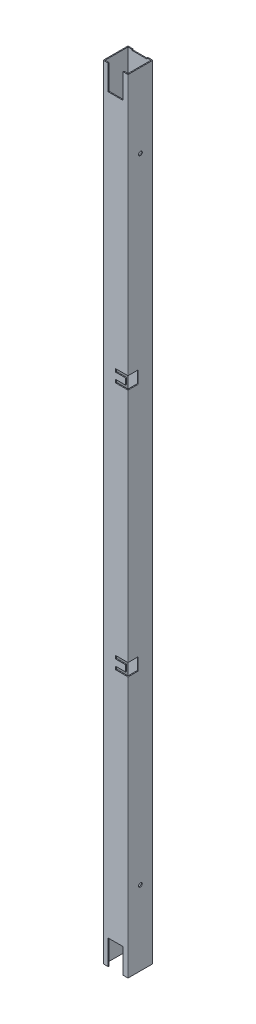
from build123d import *

# Parameters (mm, degrees)
SKETCH1_W           = 37
SKETCH1_H           = 37
BOSS_EXTRUDE1_DEPTH = 1260
SKETCH2_W           = 23.9
SKETCH2_H           = 40
CUT_EXTRUDE1_DEPTH  = 20
SKETCH3_W           = 23.9
SKETCH3_H           = 1.6
CUT_EXTRUDE2_DEPTH  = 20
CUT_EXTRUDE3_DEPTH  = 20
SKETCH5_W           = 4
SKETCH5_H           = 10
CUT_EXTRUDE4_DEPTH  = 10
LPATTERN1_COUNT     = 2
LPATTERN1_PITCH     = 400
SKETCH6_R           = 3
CUT_EXTRUDE5_DEPTH  = 1262.269202034


with BuildPart() as part:
    # Sketch1 → Boss-Extrude1 (new body)
    with BuildSketch(Plane(origin=(0, 0, 0), x_dir=(1, 0, 0), z_dir=(0, 1, 0))):
        with BuildLine():
            Line((0.5, 0), (39.5, 0))
            ThreePointArc((39.5, 0), (39.853553391, 0.146446609), (40, 0.5))
            Line((40, 0.5), (40, 39.5))
            ThreePointArc((40, 39.5), (39.853553391, 39.853553391), (39.5, 40))
            Line((39.5, 40), (0.5, 40))
            ThreePointArc((0.5, 40), (0.146446609, 39.853553391), (0, 39.5))
            Line((0, 39.5), (0, 0.5))
            ThreePointArc((0, 0.5), (0.146446609, 0.146446609), (0.5, 0))
        make_face()
        with Locations((20, 20)):
            Rectangle(SKETCH1_W, SKETCH1_H, mode=Mode.SUBTRACT)
    extrude(amount=BOSS_EXTRUDE1_DEPTH)

    # Sketch2 → Cut-Extrude1 (cut)
    with BuildSketch(Plane.XY):
        with Locations((20.05, 1240)):
            Rectangle(SKETCH2_W, SKETCH2_H)
    cut_extrude1 = extrude(amount=-CUT_EXTRUDE1_DEPTH, mode=Mode.SUBTRACT)

    # Sketch3 → Cut-Extrude2 (cut)
    with BuildSketch(Plane.XY.offset(-38.5)):
        with Locations((20.05, 1259.2)):
            Rectangle(SKETCH3_W, SKETCH3_H)
        with Locations((20.05, 1220.8)):
            Rectangle(SKETCH3_W, SKETCH3_H)
    cut_extrude2 = extrude(amount=-CUT_EXTRUDE2_DEPTH, mode=Mode.SUBTRACT)

    # Mirror1: Cut-Extrude1, Cut-Extrude2 across plane
    add(cut_extrude1.mirror(Plane.ZX.offset(630)), mode=Mode.SUBTRACT)
    add(cut_extrude2.mirror(Plane.ZX.offset(630)), mode=Mode.SUBTRACT)

    # Sketch4 → Cut-Extrude3 (cut)
    with BuildSketch(Plane(origin=(40, 0, 0), x_dir=(0, 0, -1), z_dir=(1, 0, 0))):
        Polygon((0, 840), (16.5, 840), (16.5, 820), (0, 820), (0, 825), (5, 825), (5, 835), (0, 835), align=None)
    cut_extrude3 = extrude(amount=-CUT_EXTRUDE3_DEPTH, mode=Mode.SUBTRACT)

    # Sketch5 → Cut-Extrude4 (cut)
    with BuildSketch(Plane.XY):
        with Locations((38, 830)):
            Rectangle(SKETCH5_W, SKETCH5_H)
    cut_extrude4 = extrude(amount=-CUT_EXTRUDE4_DEPTH, mode=Mode.SUBTRACT)

    # LPattern1: Cut-Extrude3, Cut-Extrude4 ×2
    with Locations(*[(0, -i * LPATTERN1_PITCH, 0) for i in range(1, LPATTERN1_COUNT)]):
        add(cut_extrude3, mode=Mode.SUBTRACT)
        add(cut_extrude4, mode=Mode.SUBTRACT)

    # Sketch6 → Cut-Extrude5 (cut, through all)
    with BuildSketch(Plane(origin=(40, 0, 0), x_dir=(0, 0, -1), z_dir=(1, 0, 0))):
        with Locations((20, 1140)):
            Circle(SKETCH6_R)
        with Locations((20, 120)):
            Circle(SKETCH6_R)
    extrude(amount=-CUT_EXTRUDE5_DEPTH, mode=Mode.SUBTRACT)


solid = part.part
